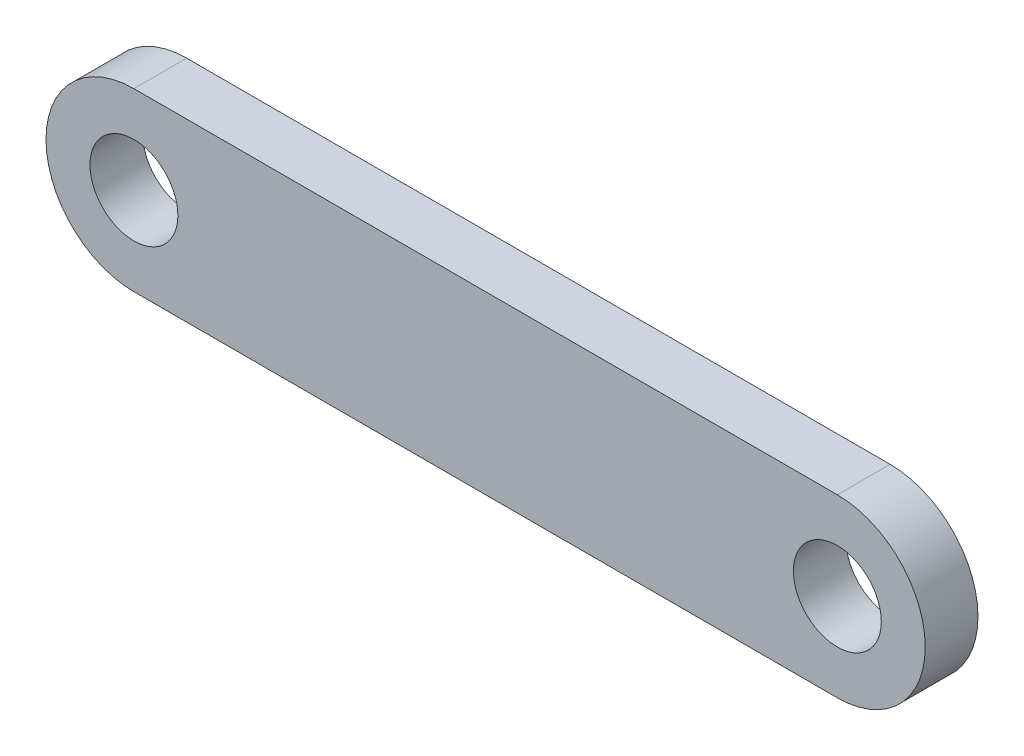
from build123d import *

# Parameters (mm, degrees)
SKETCH19_W          = 20
SKETCH19_H          = 10
BOSS_EXTRUDE4_DEPTH = 3
SKETCH22_R          = 2.5
BOSS_EXTRUDE5_DEPTH = 3


with BuildPart() as part:
    # Sketch19 → Boss-Extrude4 (new body)
    with BuildSketch(Plane.XY):
        Rectangle(SKETCH19_W, SKETCH19_H)
    boss_extrude4 = extrude(amount=-BOSS_EXTRUDE4_DEPTH)

    # Sketch22 → Boss-Extrude5 (add)
    with BuildSketch(Plane.XY):
        with BuildLine():
            Line((10, 5), (20, 5))
            ThreePointArc((20, 5), (25, 0), (20, -5))
            Line((20, -5), (10, -5))
            Line((10, -5), (10, 5))
        make_face()
        with Locations((20, 0)):
            Circle(SKETCH22_R, mode=Mode.SUBTRACT)
    boss_extrude5 = extrude(amount=-BOSS_EXTRUDE5_DEPTH)

    # Mirror2: Boss-Extrude4, Boss-Extrude5 across plane
    add(boss_extrude4.mirror(Plane.ZY))
    add(boss_extrude5.mirror(Plane.ZY))


solid = part.part
